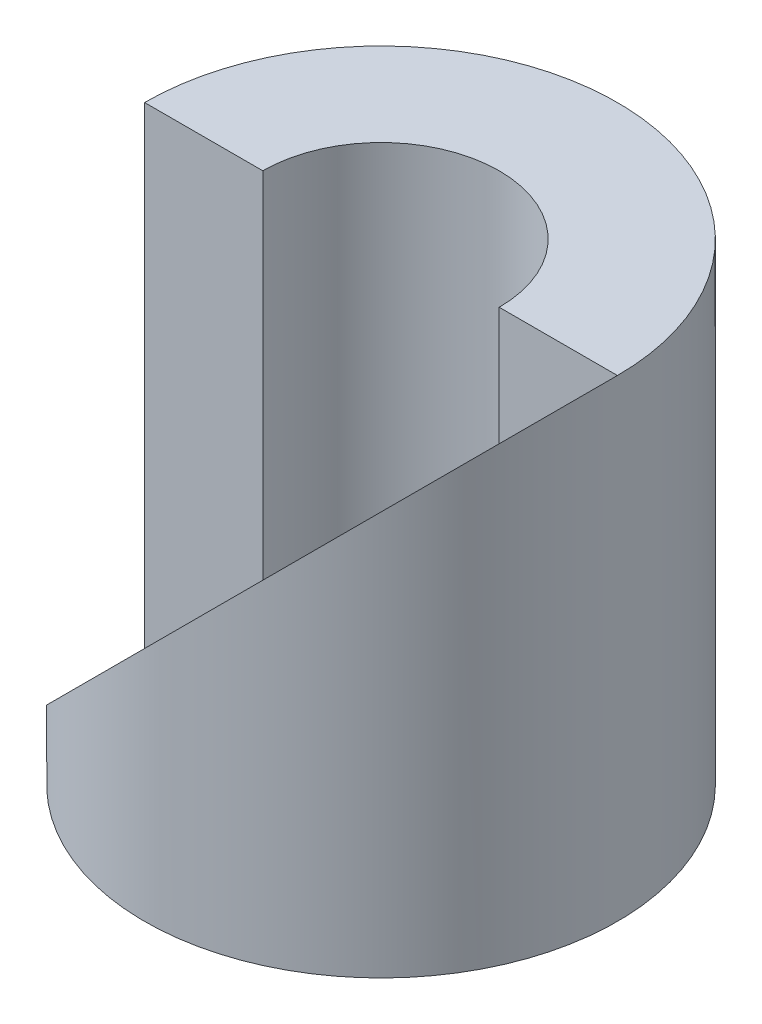
from build123d import *

# Parameters (mm, degrees)
SKETCH1_W          = 10
SKETCH1_H          = 20
SKETCH2_R          = 5
CUT_EXTRUDE4_DEPTH = 20
CUT_EXTRUDE5_DEPTH = 10


with BuildPart() as part:
    # Sketch1 → Revolve1 (revolve)
    with BuildSketch(Plane.XY):
        with Locations((5, 10)):
            Rectangle(SKETCH1_W, SKETCH1_H)
    revolve(axis=Axis((0, 0, 0), (0, 1, 0)))

    # Sketch2 → Cut-Extrude4 (cut)
    with BuildSketch(Plane(origin=(0, 20, 0), x_dir=(1, 0, 0), z_dir=(0, 1, 0))):
        Circle(SKETCH2_R)
    extrude(amount=-CUT_EXTRUDE4_DEPTH, mode=Mode.SUBTRACT)

    # Sketch4 → Cut-Extrude5 (cut)
    with BuildSketch(Plane.XY):
        Polygon((10, 20), (-10, 0), (-10, 20), align=None)
    extrude(amount=CUT_EXTRUDE5_DEPTH, mode=Mode.SUBTRACT)


solid = part.part
